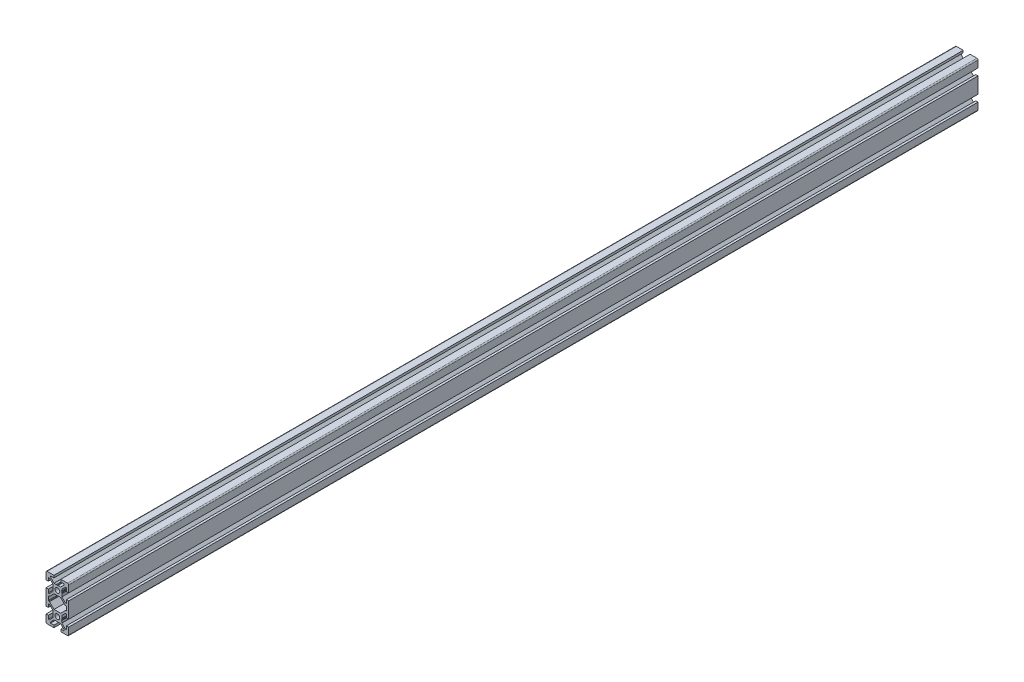
from build123d import *

# Parameters (mm, degrees)
SKETCH1_R           = 2.1
BOSS_EXTRUDE1_DEPTH = 800


with BuildPart() as part:
    # Sketch1 → Boss-Extrude1 (new body)
    with BuildSketch(Plane(origin=(0, 0, -600), x_dir=(-1, 0, 0), z_dir=(0, 0, -1))):
        with BuildLine():
            Line((10, -7), (10, 7))
            Line((10, 7), (8, 7))
            Line((8, 7), (8, 4))
            Line((8, 4), (7.060660172, 4))
            Line((7.060660172, 4), (4, 7.060660172))
            Line((4, 7.060660172), (4, 7.5))
            Line((4, 7.5), (3.750976592, 8.781114371))
            Line((3.750976592, 8.781114371), (3.933012702, 9.096410162))
            ThreePointArc((3.933012702, 9.096410162), (4, 9.346410162), (3.933012702, 9.596410162))
            Line((3.933012702, 9.596410162), (3.7, 10))
            Line((3.7, 10), (3.933012702, 10.403589838))
            ThreePointArc((3.933012702, 10.403589838), (3.982962913, 10.524180316), (4, 10.653589838))
            Line((4, 10.653589838), (4, 12.939339828))
            Line((4, 12.939339828), (7.060660172, 16))
            Line((7.060660172, 16), (8, 16))
            Line((8, 16), (8, 13))
            Line((8, 13), (10, 13))
            Line((10, 13), (10, 19))
            ThreePointArc((10, 19), (9.707106781, 19.707106781), (9, 20))
            Line((9, 20), (3, 20))
            Line((3, 20), (3, 18))
            Line((3, 18), (6, 18))
            Line((6, 18), (6, 17.060660172))
            Line((6, 17.060660172), (2.939339828, 14))
            Line((2.939339828, 14), (2.5, 14))
            Line((2.5, 14), (1.218885629, 13.750976592))
            Line((1.218885629, 13.750976592), (0.903589838, 13.933012702))
            ThreePointArc((0.903589838, 13.933012702), (0.653589838, 14), (0.403589838, 13.933012702))
            Line((0.403589838, 13.933012702), (0, 13.7))
            Line((0, 13.7), (-0.403589838, 13.933012702))
            ThreePointArc((-0.403589838, 13.933012702), (-0.524180316, 13.982962913), (-0.653589838, 14))
            Line((-0.653589838, 14), (-2.939339828, 14))
            Line((-2.939339828, 14), (-6, 17.060660172))
            Line((-6, 17.060660172), (-6, 18))
            Line((-6, 18), (-3, 18))
            Line((-3, 18), (-3, 20))
            Line((-3, 20), (-9, 20))
            ThreePointArc((-9, 20), (-9.707106781, 19.707106781), (-10, 19))
            Line((-10, 19), (-10, 13))
            Line((-10, 13), (-8, 13))
            Line((-8, 13), (-8, 16))
            Line((-8, 16), (-7.060660172, 16))
            Line((-7.060660172, 16), (-4, 12.939339828))
            Line((-4, 12.939339828), (-4, 12.5))
            Line((-4, 12.5), (-3.750976592, 11.218885629))
            Line((-3.750976592, 11.218885629), (-3.933012702, 10.903589838))
            ThreePointArc((-3.933012702, 10.903589838), (-4, 10.653589838), (-3.933012702, 10.403589838))
            Line((-3.933012702, 10.403589838), (-3.7, 10))
            Line((-3.7, 10), (-3.933012702, 9.596410162))
            ThreePointArc((-3.933012702, 9.596410162), (-3.982962913, 9.475819684), (-4, 9.346410162))
            Line((-4, 9.346410162), (-4, 7.060660172))
            Line((-4, 7.060660172), (-7.060660172, 4))
            Line((-7.060660172, 4), (-8, 4))
            Line((-8, 4), (-8, 7))
            Line((-8, 7), (-10, 7))
            Line((-10, 7), (-10, -7))
            Line((-10, -7), (-8, -7))
            Line((-8, -7), (-8, -4))
            Line((-8, -4), (-7.060660172, -4))
            Line((-7.060660172, -4), (-4, -7.060660172))
            Line((-4, -7.060660172), (-4, -9.346410162))
            ThreePointArc((-4, -9.346410162), (-3.982962913, -9.475819684), (-3.933012702, -9.596410162))
            Line((-3.933012702, -9.596410162), (-3.7, -10))
            Line((-3.7, -10), (-3.933012702, -10.403589838))
            ThreePointArc((-3.933012702, -10.403589838), (-4, -10.653589838), (-3.933012702, -10.903589838))
            Line((-3.933012702, -10.903589838), (-3.750976592, -11.218885629))
            Line((-3.750976592, -11.218885629), (-4, -12.5))
            Line((-4, -12.5), (-4, -12.939339828))
            Line((-4, -12.939339828), (-7.060660172, -16))
            Line((-7.060660172, -16), (-8, -16))
            Line((-8, -16), (-8, -13))
            Line((-8, -13), (-10, -13))
            Line((-10, -13), (-10, -19))
            ThreePointArc((-10, -19), (-9.707106781, -19.707106781), (-9, -20))
            Line((-9, -20), (-3, -20))
            Line((-3, -20), (-3, -18))
            Line((-3, -18), (-6, -18))
            Line((-6, -18), (-6, -17.060660172))
            Line((-6, -17.060660172), (-2.939339828, -14))
            Line((-2.939339828, -14), (-0.653589838, -14))
            ThreePointArc((-0.653589838, -14), (-0.524180316, -13.982962913), (-0.403589838, -13.933012702))
            Line((-0.403589838, -13.933012702), (0, -13.7))
            Line((0, -13.7), (0.403589839, -13.933012702))
            ThreePointArc((0.403589839, -13.933012702), (0.653589839, -14), (0.903589838, -13.933012702))
            Line((0.903589838, -13.933012702), (1.218885629, -13.750976592))
            Line((1.218885629, -13.750976592), (2.5, -14))
            Line((2.5, -14), (2.939339828, -14))
            Line((2.939339828, -14), (6, -17.060660172))
            Line((6, -17.060660172), (6, -18))
            Line((6, -18), (3, -18))
            Line((3, -18), (3, -20))
            Line((3, -20), (9, -20))
            ThreePointArc((9, -20), (9.707106781, -19.707106781), (10, -19))
            Line((10, -19), (10, -13))
            Line((10, -13), (8, -13))
            Line((8, -13), (8, -16))
            Line((8, -16), (7.060660172, -16))
            Line((7.060660172, -16), (4, -12.939339828))
            Line((4, -12.939339828), (4, -10.653589838))
            ThreePointArc((4, -10.653589838), (3.982962913, -10.524180316), (3.933012702, -10.403589838))
            Line((3.933012702, -10.403589838), (3.7, -10))
            Line((3.7, -10), (3.933012702, -9.596410162))
            ThreePointArc((3.933012702, -9.596410162), (4, -9.346410162), (3.933012702, -9.096410162))
            Line((3.933012702, -9.096410162), (3.750976592, -8.781114371))
            Line((3.750976592, -8.781114371), (4, -7.5))
            Line((4, -7.5), (4, -7.060660172))
            Line((4, -7.060660172), (7.060660172, -4))
            Line((7.060660172, -4), (8, -4))
            Line((8, -4), (8, -7))
            Line((8, -7), (10, -7))
        make_face()
        with Locations((0, -10)):
            Circle(SKETCH1_R, mode=Mode.SUBTRACT)
        with Locations((0, 10)):
            Circle(SKETCH1_R, mode=Mode.SUBTRACT)
        with BuildLine():
            Line((8, 1.7), (8, -1.7))
            ThreePointArc((8, -1.7), (7.912132034, -1.912132034), (7.7, -2))
            Line((7.7, -2), (7.063603897, -2))
            ThreePointArc((7.063603897, -2), (6.948798867, -2.02283614), (6.851471863, -2.087867966))
            Line((6.851471863, -2.087867966), (2.939339828, -6))
            Line((2.939339828, -6), (-2.939339828, -6))
            Line((-2.939339828, -6), (-6.851471863, -2.087867966))
            ThreePointArc((-6.851471863, -2.087867966), (-6.948798867, -2.02283614), (-7.063603897, -2))
            Line((-7.063603897, -2), (-7.7, -2))
            ThreePointArc((-7.7, -2), (-7.912132034, -1.912132034), (-8, -1.7))
            Line((-8, -1.7), (-8, 1.7))
            ThreePointArc((-8, 1.7), (-7.912132034, 1.912132034), (-7.7, 2))
            Line((-7.7, 2), (-7.063603897, 2))
            ThreePointArc((-7.063603897, 2), (-6.948798867, 2.02283614), (-6.851471863, 2.087867966))
            Line((-6.851471863, 2.087867966), (-2.939339828, 6))
            Line((-2.939339828, 6), (2.939339828, 6))
            Line((2.939339828, 6), (6.851471863, 2.087867966))
            ThreePointArc((6.851471863, 2.087867966), (6.948798867, 2.02283614), (7.063603897, 2))
            Line((7.063603897, 2), (7.7, 2))
            ThreePointArc((7.7, 2), (7.912132034, 1.912132034), (8, 1.7))
        make_face(mode=Mode.SUBTRACT)
    extrude(amount=-BOSS_EXTRUDE1_DEPTH)


solid = part.part
